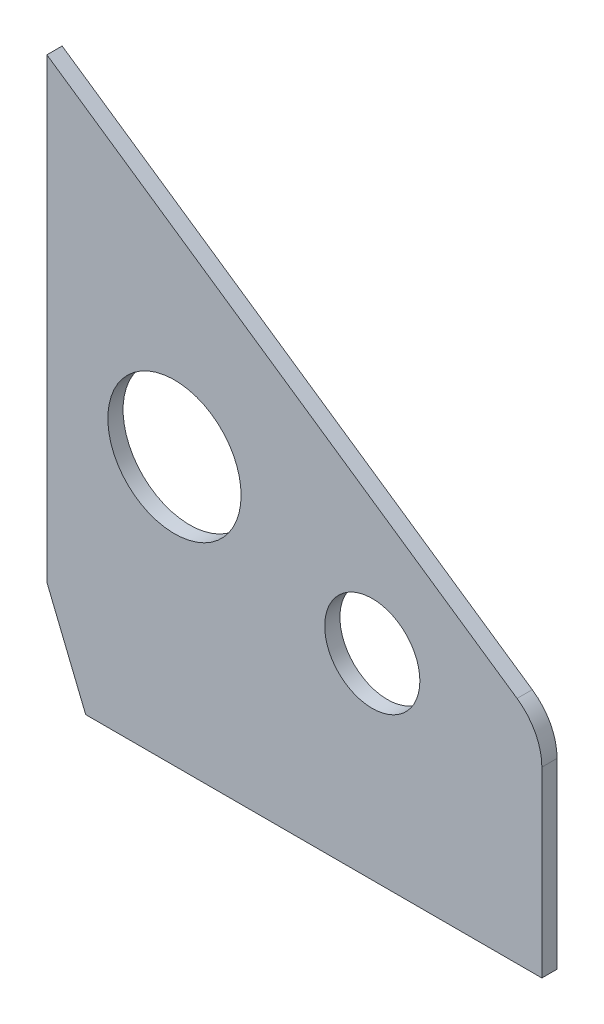
from build123d import *

# Parameters (mm, degrees)
SKETCH_1_R      = 17.5
SKETCH_1_R_2    = 12.5
EXTRUDE_1_DEPTH = 4


with BuildPart() as part:
    # 草图1 → 凸台-拉伸1 (new body)
    with BuildSketch(Plane.XY):
        with BuildLine():
            Line((-26.716521465, 615.290207127), (-146.53444515, 615.290207127))
            Line((-146.53444515, 615.290207127), (-156.716521465, 640.290207127))
            Line((-156.716521465, 640.290207127), (-156.716521465, 760.290207127))
            Line((-156.716521465, 760.290207127), (-33.233977794, 675.622063649))
            ThreePointArc((-33.233977794, 675.622063649), (-28.445535159, 670.242358457), (-26.716521465, 663.250869168))
            Line((-26.716521465, 663.250869168), (-26.716521465, 615.290207127))
        make_face()
        with Locations((-123.214216797, 685.589410404)):
            Circle(SKETCH_1_R, mode=Mode.SUBTRACT)
        with Locations((-71.258091401, 666.840828083)):
            Circle(SKETCH_1_R_2, mode=Mode.SUBTRACT)
    extrude(amount=EXTRUDE_1_DEPTH)


solid = part.part
